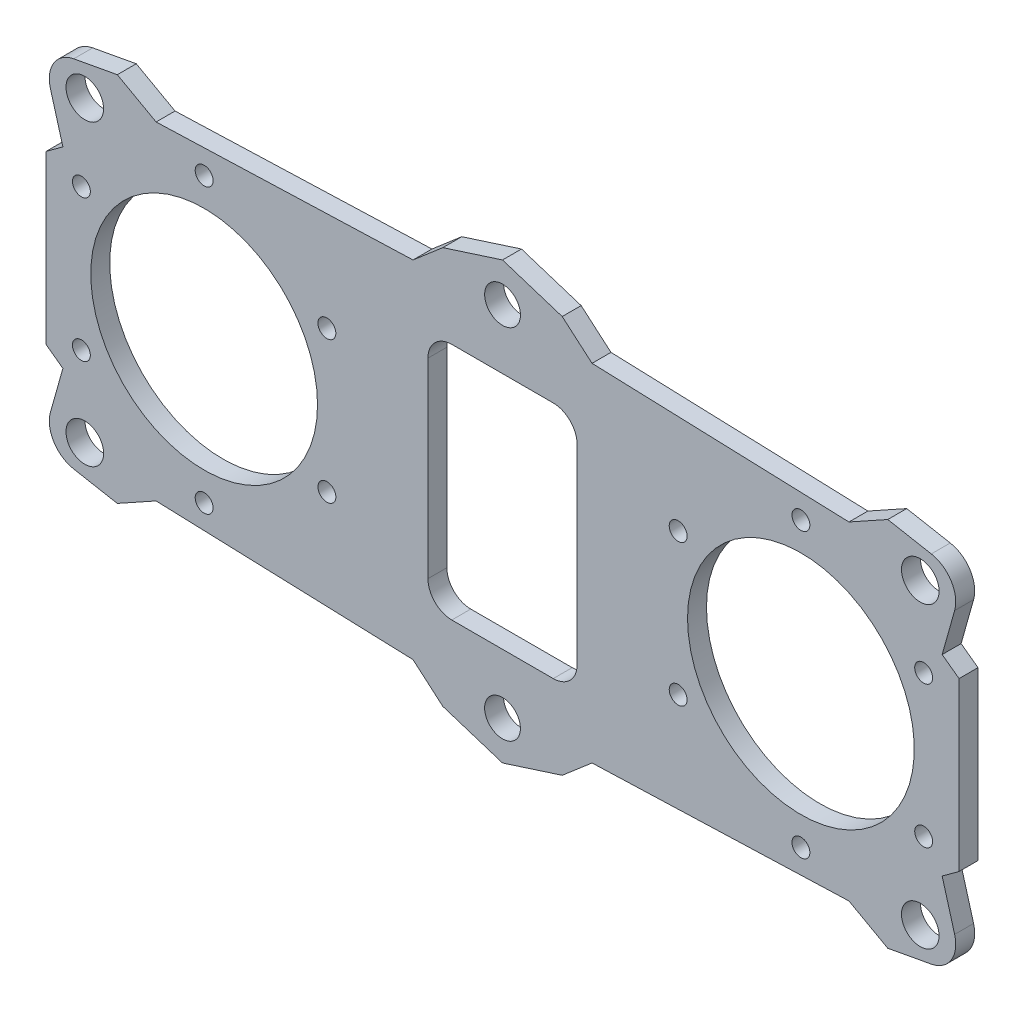
from build123d import *

# Parameters (mm, degrees)
SKETCH1_R           = 3
SKETCH1_R_2         = 19
BOSS_EXTRUDE1_DEPTH = 3.175
CUT_EXTRUDE1_DEPTH  = 4.175
SKETCH3_R           = 3.15
BOSS_EXTRUDE2_DEPTH = 3.175
FILLET1_R           = 5
SKETCH4_R           = 1.5
CUT_EXTRUDE2_DEPTH  = 4.175


with BuildPart() as part:
    # Sketch1 → Boss-Extrude1 (new body)
    with BuildSketch(Plane.XY):
        Polygon((0, 36.5), (-10, 33.28960264), (-15, 29), (-58.05, 27.5), (-76.5, 14), (-76.5, -14), (-58.05, -27.5), (-15, -29), (-10, -33.28960264), (0, -36.5), (10, -33.28960264), (15, -29), (58.05, -27.5), (76.5, -14), (76.5, 14), (58.05, 27.5), (15, 29), (10, 33.28960264), align=None)
        with Locations((0, 30)):
            Circle(SKETCH1_R, mode=Mode.SUBTRACT)
        with Locations((-50, 0)):
            Circle(SKETCH1_R_2, mode=Mode.SUBTRACT)
        with Locations((50, 0)):
            Circle(SKETCH1_R_2, mode=Mode.SUBTRACT)
        with Locations((0, -30)):
            Circle(SKETCH1_R, mode=Mode.SUBTRACT)
    extrude(amount=BOSS_EXTRUDE1_DEPTH)

    # Sketch2 → Cut-Extrude1 (cut, through all)
    with BuildSketch(Plane.XY.offset(3.175)):
        with BuildLine():
            Line((8.5, 20), (-8.5, 20))
            ThreePointArc((-8.5, 20), (-11.328427125, 18.828427125), (-12.5, 16))
            Line((-12.5, 16), (-12.5, -16))
            ThreePointArc((-12.5, -16), (-11.328427125, -18.828427125), (-8.5, -20))
            Line((-8.5, -20), (8.5, -20))
            ThreePointArc((8.5, -20), (11.328427125, -18.828427125), (12.5, -16))
            Line((12.5, -16), (12.5, 16))
            ThreePointArc((12.5, 16), (11.328427125, 18.828427125), (8.5, 20))
        make_face()
    extrude(amount=-CUT_EXTRUDE1_DEPTH, mode=Mode.SUBTRACT)

    # Sketch3 → Boss-Extrude2 (add)
    with BuildSketch(Plane.XY.offset(3.175)):
        Polygon((-58.05, 27.5), (-64.551915182, 31.10998542), (-77.245081729, 28.773819798), (-73.669390597, 16.071177612), align=None)
        with Locations((-70, 25)):
            Circle(SKETCH3_R, mode=Mode.SUBTRACT)
        Polygon((73.669390597, 16.071177612), (58.05, 27.5), (64.551915182, 31.10998542), (77.245081729, 28.773819798), align=None)
        with Locations((70, 25)):
            Circle(SKETCH3_R, mode=Mode.SUBTRACT)
        Polygon((58.05, -27.5), (64.551915182, -31.10998542), (77.245081729, -28.773819798), (73.669390597, -16.071177612), align=None)
        with Locations((70, -25)):
            Circle(SKETCH3_R, mode=Mode.SUBTRACT)
        Polygon((-73.669390597, -16.071177612), (-58.05, -27.5), (-64.551915182, -31.10998542), (-77.245081729, -28.773819798), align=None)
        with Locations((-70, -25)):
            Circle(SKETCH3_R, mode=Mode.SUBTRACT)
    extrude(amount=-BOSS_EXTRUDE2_DEPTH)

    # Fillet1
    fillet1_edges = [part.edges().sort_by_distance(p)[0] for p in [
        (77.245081729, 28.773819798, 1.5875),
        (77.245081729, -28.773819798, 1.5875),
        (-77.245081729, -28.773819798, 1.5875),
        (-77.245081729, 28.773819798, 1.5875),
    ]]
    fillet(fillet1_edges, radius=FILLET1_R)

    # Sketch4 → Cut-Extrude2 (cut, through all)
    with BuildSketch(Plane.XY.offset(3.175)):
        with Locations((-50, 23.75)):
            Circle(SKETCH4_R)
        with Locations((-70.56810334, 11.875)):
            Circle(SKETCH4_R)
        with Locations((-70.56810334, -11.875)):
            Circle(SKETCH4_R)
        with Locations((-50, -23.75)):
            Circle(SKETCH4_R)
        with Locations((-29.43189666, -11.875)):
            Circle(SKETCH4_R)
        with Locations((-29.43189666, 11.875)):
            Circle(SKETCH4_R)
        with Locations((29.43189666, 11.875)):
            Circle(SKETCH4_R)
        with Locations((29.43189666, -11.875)):
            Circle(SKETCH4_R)
        with Locations((50, -23.75)):
            Circle(SKETCH4_R)
        with Locations((70.56810334, -11.875)):
            Circle(SKETCH4_R)
        with Locations((70.56810334, 11.875)):
            Circle(SKETCH4_R)
        with Locations((50, 23.75)):
            Circle(SKETCH4_R)
    extrude(amount=-CUT_EXTRUDE2_DEPTH, mode=Mode.SUBTRACT)


solid = part.part
